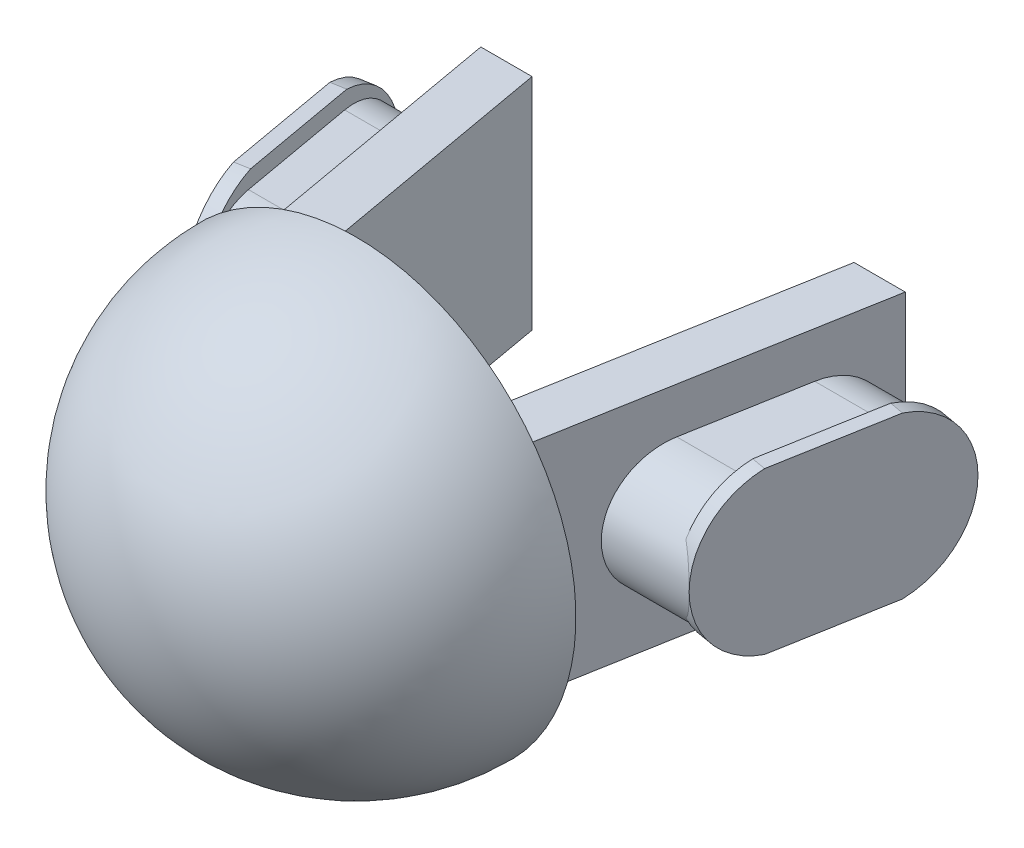
from build123d import *

# Parameters (mm, degrees)
SKETCH4_W           = 7
SKETCH4_H           = 7
BOSS_EXTRUDE2_DEPTH = 2.55
REVOLVE1_ANGLE      = 180
SKETCH2_W           = 3.7
SKETCH2_H           = 3.7
CUT_EXTRUDE1_DEPTH  = 1.5
BOSS_EXTRUDE6_DEPTH = 7.5
BOSS_EXTRUDE7_DEPTH = 22.5
CUT_EXTRUDE2_DEPTH  = 22.5
BOSS_EXTRUDE8_DEPTH = 1


with BuildPart() as part:
    # Sketch4 → Boss-Extrude2 (new body)
    with BuildSketch(Plane(origin=(0, 0, 0), x_dir=(0, 1, 0), z_dir=(0, 0, 1))):
        Rectangle(SKETCH4_W, SKETCH4_H)
    extrude(amount=BOSS_EXTRUDE2_DEPTH)

    # Sketch5 → Revolve1 (revolve)
    with BuildSketch(Plane.XY.offset(2.55)):
        with BuildLine():
            Line((0, 15), (0, -15))
            ThreePointArc((0, -15), (15, 0), (0, 15))
        make_face()
    revolve(axis=Axis((0, -1000, 2.55), (0, -1, 0)), revolution_arc=REVOLVE1_ANGLE)

    # Sketch2 → Cut-Extrude1 (cut)
    with BuildSketch(Plane(origin=(0, 0, 0), x_dir=(0, 1, 0), z_dir=(0, 0, 1))):
        Rectangle(SKETCH2_W, SKETCH2_H)
    extrude(amount=CUT_EXTRUDE1_DEPTH, mode=Mode.SUBTRACT)

    # Sketch13 → Boss-Extrude6 (add, symmetric)
    with BuildSketch(Plane(origin=(0, 0, 0), x_dir=(-1, 0, 0), z_dir=(0, 1, 0))):
        Polygon((-6.9, 2.55), (-10.996923994, -20.45), (-14.496923994, -20.45), (-10.4, 2.55), align=None)
        Polygon((10.996923994, -20.45), (14.496923994, -20.45), (10.4, 2.55), (6.9, 2.55), align=None)
    extrude(amount=BOSS_EXTRUDE6_DEPTH, both=True)

    # Sketch14 → Boss-Extrude7 (add, symmetric)
    with BuildSketch(Plane.YZ):
        with BuildLine():
            Line((4.375, -7.2), (4.375, -15.2))
            ThreePointArc((4.375, -15.2), (0, -19.575), (-4.375, -15.2))
            Line((-4.375, -15.2), (-4.375, -7.2))
            ThreePointArc((-4.375, -7.2), (0, -2.825), (4.375, -7.2))
        make_face()
    extrude(amount=BOSS_EXTRUDE7_DEPTH, both=True)

    # Sketch15 → Cut-Extrude2 (cut, symmetric)
    with BuildSketch(Plane(origin=(0, 0, 0), x_dir=(-1, 0, 0), z_dir=(0, 1, 0))):
        Polygon((-7.857433325, -2.825), (7.857433325, -2.825), (10.996923994, -20.45), (-10.996923994, -20.45), align=None)
        Polygon((-17.357433325, -2.825), (-20.341062755, -19.575), (-22.5, -19.575), (-22.5, -2.825), align=None)
        Polygon((20.341062755, -19.575), (22.5, -19.575), (22.5, -2.825), (17.357433325, -2.825), align=None)
    extrude(amount=CUT_EXTRUDE2_DEPTH, both=True, mode=Mode.SUBTRACT)

    # Sketch16 → Boss-Extrude8 (add)
    with BuildSketch(Plane(origin=(-16.33589799, 0, 2.909866628), x_dir=(0, -1, 0), z_dir=(-0.98450318, 0, 0.175366726))):
        with BuildLine():
            Line((5.5, -10.269003527), (5.5, -18.39492954))
            ThreePointArc((5.5, -18.39492954), (0, -22.838795329), (-5.5, -18.39492954))
            Line((-5.5, -18.39492954), (-5.5, -10.269003527))
            ThreePointArc((-5.5, -10.269003527), (0, -5.825137739), (5.5, -10.269003527))
        make_face()
    boss_extrude8 = extrude(amount=-BOSS_EXTRUDE8_DEPTH)

    # Mirror1: Boss-Extrude8 across plane
    add(boss_extrude8.mirror(Plane(origin=(0, 0, 0), x_dir=(0, 0, 1), z_dir=(1, 0, 0))))


solid = part.part
